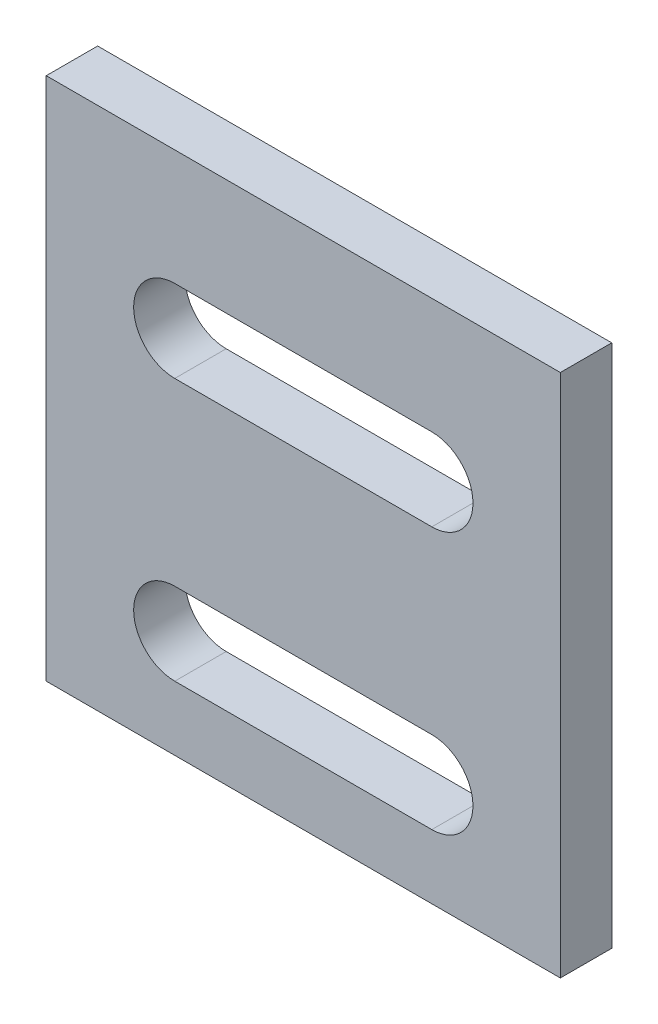
from build123d import *

# Parameters (mm, degrees)
SKETCH_1_W      = 20
SKETCH_1_H      = 20.4
EXTRUDE_1_DEPTH = 2


with BuildPart() as part:
    # 草图1 → 凸台-拉伸1 (new body)
    with BuildSketch(Plane.XY):
        with Locations((-8.175518001, 7.839742025)):
            Rectangle(SKETCH_1_W, SKETCH_1_H)
        with BuildLine():
            Line((-13.175518001, 13.539742025), (-3.175518001, 13.539742025))
            ThreePointArc((-3.175518001, 13.539742025), (-1.575518001, 11.939742025), (-3.175518001, 10.339742025))
            Line((-3.175518001, 10.339742025), (-13.175518001, 10.339742025))
            ThreePointArc((-13.175518001, 10.339742025), (-14.775518001, 11.939742025), (-13.175518001, 13.539742025))
        make_face(mode=Mode.SUBTRACT)
        with BuildLine():
            Line((-13.175518001, 0.139742025), (-3.175518001, 0.139742025))
            ThreePointArc((-3.175518001, 0.139742025), (-1.575518001, 1.739742025), (-3.175518001, 3.339742025))
            Line((-3.175518001, 3.339742025), (-13.175518001, 3.339742025))
            ThreePointArc((-13.175518001, 3.339742025), (-14.775518001, 1.739742025), (-13.175518001, 0.139742025))
        make_face(mode=Mode.SUBTRACT)
    extrude(amount=EXTRUDE_1_DEPTH)


solid = part.part
